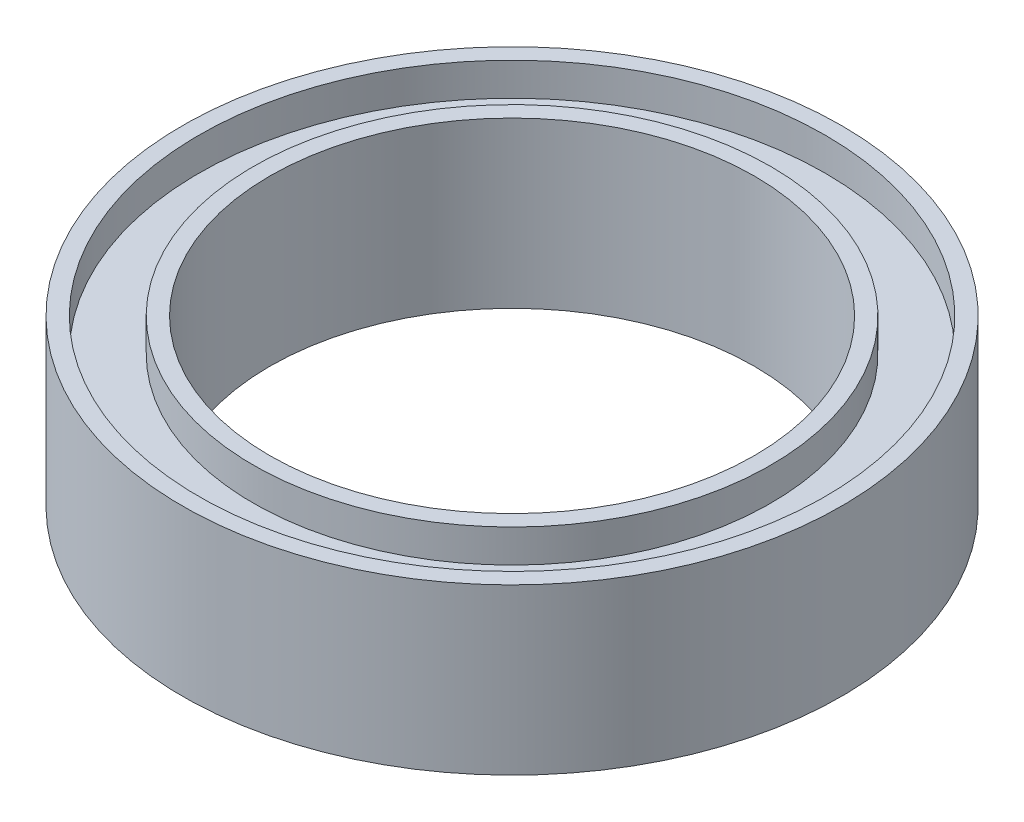
from build123d import *


with BuildPart() as part:
    # Sketch2 → Revolve1 (revolve)
    with BuildSketch(Plane.XY):
        Polygon((21.5, 50), (26.5, 50), (26.5, 0), (21.5, 0), (21.5, 32), (5, 32), (5, 0), (0, 0), (0, 50), (5, 50), (5, 40), (21.5, 40), align=None)
    revolve(axis=Axis((-73.5, 0, 0), (0, 1, 0)))


solid = part.part
